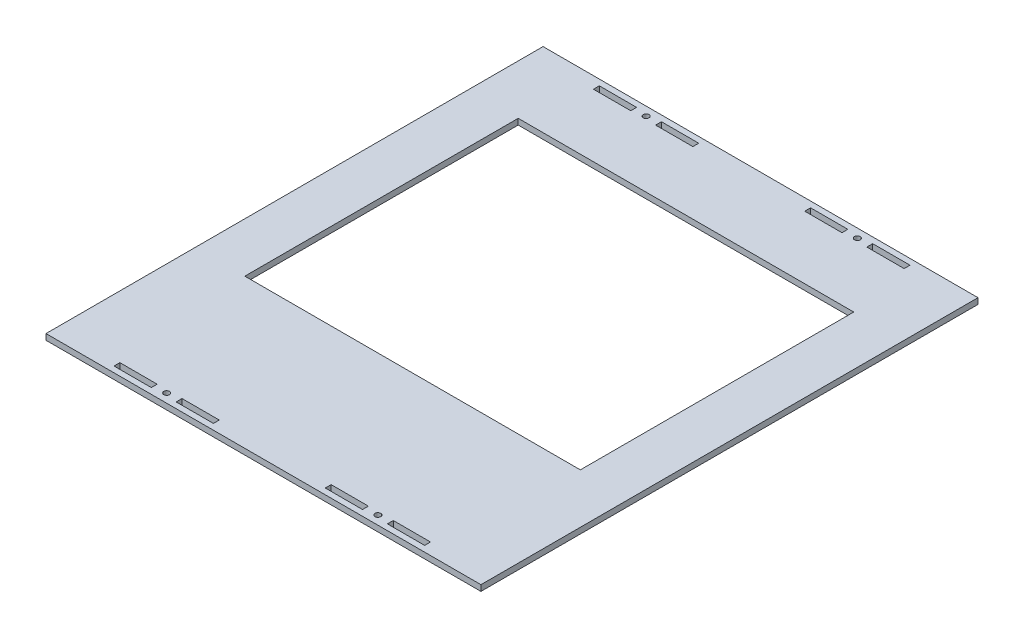
from build123d import *

# Parameters (mm, degrees)
SKETCH2_W             = 222.25
SKETCH2_H             = 254
BOSS_EXTRUDE1_DEPTH   = 3
SKETCH5_W             = 19.05
SKETCH5_H             = 3
SKETCH5_W_2           = 19.051189761
CUT_EXTRUDE1_DEPTH    = 4
F_4_CLEARANCE_HOLE2_D = 2.9464
SKETCH8_W             = 171.45
SKETCH8_H             = 139.7
CUT_EXTRUDE2_DEPTH    = 4


with BuildPart() as part:
    # Sketch2 → Boss-Extrude1 (new body)
    with BuildSketch(Plane(origin=(0, 0, 0), x_dir=(1, 0, 0), z_dir=(0, 1, 0))):
        with Locations((111.125, 127)):
            Rectangle(SKETCH2_W, SKETCH2_H)
    extrude(amount=BOSS_EXTRUDE1_DEPTH)

    # Sketch5 → Cut-Extrude1 (cut, through all)
    with BuildSketch(Plane(origin=(0, 3, 0), x_dir=(1, 0, 0), z_dir=(0, 1, 0))):
        with Locations((41.275, 249.5)):
            Rectangle(SKETCH5_W, SKETCH5_H)
        with Locations((73.025594881, 249.5)):
            Rectangle(SKETCH5_W_2, SKETCH5_H)
        with Locations((149.22440512, 249.5)):
            Rectangle(SKETCH5_W_2, SKETCH5_H)
        with Locations((180.975, 249.5)):
            Rectangle(SKETCH5_W, SKETCH5_H)
        with Locations((41.275, 4.5)):
            Rectangle(SKETCH5_W, SKETCH5_H)
        with Locations((73.025594881, 4.5)):
            Rectangle(SKETCH5_W_2, SKETCH5_H)
        with Locations((180.975, 4.5)):
            Rectangle(SKETCH5_W, SKETCH5_H)
        with Locations((149.22440512, 4.5)):
            Rectangle(SKETCH5_W_2, SKETCH5_H)
    extrude(amount=-CUT_EXTRUDE1_DEPTH, mode=Mode.SUBTRACT)

    # #4 Clearance Hole2 (through all)
    with Locations(Plane(origin=(0, 3, 0), x_dir=(1, 0, 0), z_dir=(0, 1, 0))):
        with Locations((57.15, 249.5), (165.1, 249.5), (165.1, 4.5), (57.15, 4.5)):
            Hole(F_4_CLEARANCE_HOLE2_D / 2)

    # Sketch8 → Cut-Extrude2 (cut, through all)
    with BuildSketch(Plane(origin=(0, 3, 0), x_dir=(1, 0, 0), z_dir=(0, 1, 0))):
        with Locations((111.125, 146.05)):
            Rectangle(SKETCH8_W, SKETCH8_H)
    extrude(amount=-CUT_EXTRUDE2_DEPTH, mode=Mode.SUBTRACT)


solid = part.part
